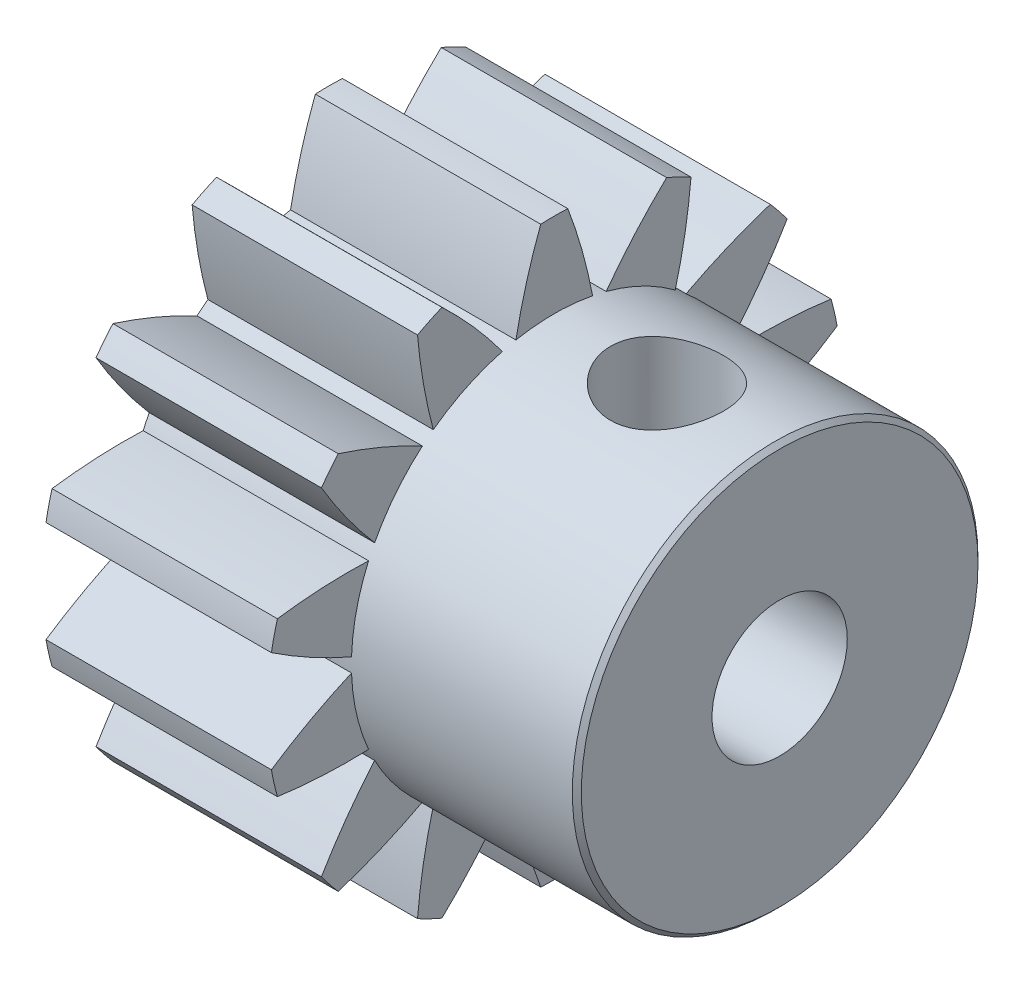
from build123d import *

# Parameters (mm, degrees)
SKETCH1_R           = 4.5
SKETCH1_R_2         = 1.5
BOSS_EXTRUDE1_DEPTH = 10
BOSS_EXTRUDE2_DEPTH = 5
CIRPATTERN1_COUNT   = 14
CHAMFER1_SIZE       = 0.1
SKETCH2_R           = 1.25
CUT_EXTRUDE1_DEPTH  = 14.417030319
CUT_EXTRUDE2_DEPTH  = 0.01


with BuildPart() as part:
    # Sketch1 → Boss-Extrude1 (new body)
    with BuildSketch(Plane(origin=(0, 0, 0), x_dir=(0, 0, -1), z_dir=(1, 0, 0))):
        Circle(SKETCH1_R)
        Circle(SKETCH1_R_2, mode=Mode.SUBTRACT)
    extrude(amount=BOSS_EXTRUDE1_DEPTH)

    # Sketch1_3 → Boss-Extrude2 (add)
    with BuildSketch(Plane(origin=(0, 0, 0), x_dir=(0, 0, -1), z_dir=(1, 0, 0))):
        with BuildLine():
            ThreePointArc((-0.85, 4.418993098), (0, 3.393196379), (0.85, 4.418993098))
            ThreePointArc((0.85, 4.418993098), (0.617982771, 5.405595095), (0.3, 6.367937264))
            ThreePointArc((0.3, 6.367937264), (0, 6.375), (-0.3, 6.367937264))
            ThreePointArc((-0.3, 6.367937264), (-0.617982771, 5.405595095), (-0.85, 4.418993098))
        make_face()
    boss_extrude2 = extrude(amount=BOSS_EXTRUDE2_DEPTH)

    # CirPattern1: Boss-Extrude2 ×14 about axis
    cirpattern1_axis = Axis((10, 0, 0), (-1, 0, 0))
    for i in range(1, CIRPATTERN1_COUNT):
        add(boss_extrude2.rotate(cirpattern1_axis, i * 360 / CIRPATTERN1_COUNT))

    # Chamfer1
    chamfer1_edges = [part.edges().sort_by_distance(p)[0] for p in [
        (10, 0, 4.5),
    ]]
    chamfer(chamfer1_edges, length=CHAMFER1_SIZE)

    # Sketch2 → Cut-Extrude1 (cut, through all)
    with BuildSketch(Plane(origin=(0, 0, 0), x_dir=(1, 0, 0), z_dir=(0, 1, 0))):
        with Locations((7.5, 0)):
            Circle(SKETCH2_R)
    extrude(amount=CUT_EXTRUDE1_DEPTH, mode=Mode.SUBTRACT)

    # Sketch3 → Cut-Extrude2 (cut)
    # profile 1 of 6: a face of its own
    with BuildSketch(Plane.ZY):
        with BuildLine():
            Line((3.696183293, 1.353338585), (3.76559435, 1.064576566))
            add(Edge.make_bspline(
                [(3.76559435, 1.064576566), (3.77037167, 1.044660811), (3.779502695, 1.006595267), (3.791496189, 0.951772239), (3.80174489, 0.90189395), (3.810274475, 0.856951074), (3.816624635, 0.81685637), (3.821136168, 0.781692215), (3.824228842, 0.751331364), (3.824407225, 0.732651366), (3.824488581, 0.724131854)],
                knots=[0, 0, 0, 0, 1.420106792, 2.7142901, 3.891117153, 4.950882503, 5.886029369, 6.705261392, 7.409499822, 8, 8, 8, 8], degree=3))
            add(Edge.make_bspline(
                [(3.824488581, 0.724131854), (3.824298798, 0.713299913), (3.823923222, 0.691863781), (3.819683757, 0.660265307), (3.81389973, 0.629564749), (3.805288674, 0.599860763), (3.794631953, 0.57103397), (3.781089101, 0.543290147), (3.766005343, 0.516076204), (3.747841429, 0.490412668), (3.727860243, 0.465999654), (3.705487855, 0.44369448), (3.681058056, 0.423448751), (3.654386915, 0.405450772), (3.62590372, 0.389047347), (3.59487265, 0.37536351), (3.562036386, 0.363164909), (3.538993849, 0.357242315), (3.5273131, 0.354240027)],
                knots=[0, 0, 0, 0, 1.009742343, 1.998254008, 2.969393097, 3.921652167, 4.879577864, 5.83238679, 6.798885613, 7.778615852, 8.760748813, 9.738516915, 10.720649875, 11.715762546, 12.736724355, 13.782145576, 14.875722736, 16, 16, 16, 16], degree=3))
            add(Edge.make_bspline(
                [(3.5273131, 0.354240027), (3.515426007, 0.351662324), (3.492182734, 0.346622046), (3.457416611, 0.342136571), (3.423669484, 0.340289689), (3.390780456, 0.341064117), (3.358902983, 0.345019169), (3.328044085, 0.351687405), (3.298163619, 0.360883889), (3.269628328, 0.373397844), (3.242169647, 0.388136984), (3.216117148, 0.405210027), (3.191527287, 0.424564609), (3.168764436, 0.446424515), (3.146911749, 0.470034725), (3.127180501, 0.496540221), (3.108396609, 0.524872618), (3.097655659, 0.545246012), (3.092216946, 0.555562143)],
                knots=[0, 0, 0, 0, 1.117505492, 2.185099841, 3.217588868, 4.22136312, 5.204451967, 6.165000207, 7.119974362, 8.072460675, 9.023878779, 9.981334311, 10.93163842, 11.895357376, 12.879307825, 13.884558372, 14.928839729, 16, 16, 16, 16], degree=3))
            add(Edge.make_bspline(
                [(3.092216946, 0.555562143), (3.088132773, 0.564140946), (3.079162793, 0.582982381), (3.066363201, 0.61455049), (3.053264076, 0.651786736), (3.039934444, 0.694593475), (3.025453638, 0.74262799), (3.010388619, 0.796186534), (2.995167454, 0.855443572), (2.985096318, 0.896896209), (2.979837139, 0.918542912)],
                knots=[0, 0, 0, 0, 0.599028215, 1.315632346, 2.146623072, 3.087410317, 4.142418399, 5.310125699, 6.595338879, 8, 8, 8, 8], degree=3))
            Line((2.979837139, 0.918542912), (2.954897235, 1.022208777))
            Line((2.954897235, 1.022208777), (2.280618389, 0.860249643))
            Line((2.280618389, 0.860249643), (2.24576262, 1.005081373))
            Line((2.24576262, 1.005081373), (3.696183293, 1.353338585))
        make_face()
        with BuildLine():
            Line((3.590113581, 1.174853008), (3.097024639, 1.056463585))
            Line((3.097024639, 1.056463585), (3.152914062, 0.810069354))
            add(Edge.make_bspline(
                [(3.152914062, 0.810069354), (3.155860013, 0.798135216), (3.161572464, 0.77499391), (3.170787666, 0.741795387), (3.180458979, 0.711242954), (3.190311394, 0.68349567), (3.20016808, 0.658216601), (3.210625253, 0.63589994), (3.221184781, 0.616088129), (3.235303155, 0.593596201), (3.255012815, 0.569205569), (3.28240234, 0.54502088), (3.312831572, 0.525158641), (3.346191435, 0.510233989), (3.381428388, 0.500235604), (3.417811812, 0.496192703), (3.454710971, 0.496763884), (3.478984012, 0.501689668), (3.491255408, 0.504179931)],
                knots=[0, 0, 0, 0, 1.134875419, 2.20061973, 3.180367898, 4.092916849, 4.918894509, 5.684255937, 6.366939641, 6.990370405, 8.134214937, 9.247753563, 10.350682225, 11.4764791, 12.609544629, 13.717578753, 14.84610686, 16, 16, 16, 16], degree=3))
            add(Edge.make_bspline(
                [(3.491255408, 0.504179931), (3.503092586, 0.507547531), (3.526492555, 0.514204669), (3.559327761, 0.530052041), (3.588968678, 0.550933669), (3.61589329, 0.575327399), (3.63906331, 0.6031269), (3.65728075, 0.633636901), (3.670048896, 0.666342631), (3.676468398, 0.695326093), (3.678684033, 0.720386305), (3.679413699, 0.741673184), (3.677894561, 0.765335193), (3.675516304, 0.791287317), (3.671981132, 0.81979835), (3.666358891, 0.850495829), (3.659855866, 0.883701137), (3.654494688, 0.90644036), (3.651712139, 0.918242431)],
                knots=[0, 0, 0, 0, 1.164641121, 2.302285783, 3.434374343, 4.589930822, 5.735859126, 6.850830588, 7.941791502, 9.049468073, 9.650101826, 10.324224693, 11.065489516, 11.894683428, 12.794070503, 13.786450834, 14.851127726, 16, 16, 16, 16], degree=3))
            Line((3.651712139, 0.918242431), (3.590113581, 1.174853008))
        make_face(mode=Mode.SUBTRACT)
    # profile 2 of 6: a face of its own
    with BuildSketch(Plane.ZY):
        with BuildLine():
            Line((2.38117998, 2.522545505), (2.288331422, 2.631019063))
            add(Edge.make_bspline(
                [(2.288331422, 2.631019063), (2.302558409, 2.642112094), (2.33055903, 2.663944667), (2.375210694, 2.691415342), (2.420460909, 2.714512141), (2.466592113, 2.732774811), (2.513802566, 2.745563434), (2.561646804, 2.754254193), (2.610505363, 2.757318588), (2.659696126, 2.756246137), (2.708421688, 2.750291871), (2.755554129, 2.73961618), (2.800935874, 2.72509532), (2.843957761, 2.705249524), (2.885266368, 2.681547334), (2.923952309, 2.652568252), (2.961314634, 2.619934911), (2.98369129, 2.59500801), (2.995062191, 2.582341178)],
                knots=[0, 0, 0, 0, 1.096280449, 2.157627114, 3.181764335, 4.182693667, 5.168236385, 6.151518248, 7.134366187, 8.139585183, 9.139773059, 10.113502013, 11.074577628, 12.031262583, 12.989168109, 13.964894965, 14.965842827, 16, 16, 16, 16], degree=3))
            add(Edge.make_bspline(
                [(2.995062191, 2.582341178), (3.005771135, 2.569437807), (3.026762737, 2.544144701), (3.052703797, 2.503219512), (3.074521409, 2.46196667), (3.092045324, 2.419953989), (3.103978555, 2.376824098), (3.111198213, 2.332899661), (3.114005706, 2.288184261), (3.111709932, 2.243102154), (3.10553359, 2.198632548), (3.095252359, 2.155799971), (3.081418003, 2.115037727), (3.063893519, 2.076241667), (3.042486634, 2.039529718), (3.017377252, 2.004869391), (2.988804455, 1.97203598), (2.9670349, 1.952513676), (2.955999691, 1.942617621)],
                knots=[0, 0, 0, 0, 1.123473806, 2.202226089, 3.241768798, 4.250854748, 5.24822596, 6.235412689, 7.231335351, 8.246661292, 9.25735549, 10.238100213, 11.19606276, 12.139958311, 13.088074462, 14.040676712, 15.006799063, 16, 16, 16, 16], degree=3))
            add(Edge.make_bspline(
                [(2.955999691, 1.942617621), (2.93970516, 1.929521972), (2.907370194, 1.90353489), (2.853152721, 1.873074713), (2.79606504, 1.84896867), (2.745240087, 1.835204472), (2.701432735, 1.827328857), (2.664118437, 1.822599638), (2.622606522, 1.819159744), (2.576925252, 1.816398391), (2.527023392, 1.814989671), (2.472923447, 1.814714854), (2.414623441, 1.815704178), (2.374367613, 1.816965107), (2.353535749, 1.817617621)],
                knots=[0, 0, 0, 0, 1.189950895, 2.361345635, 3.530985644, 4.715347917, 5.353727711, 6.067617875, 6.858549572, 7.727965667, 8.676229375, 9.704016878, 10.811858751, 12, 12, 12, 12], degree=3))
            Line((2.353535749, 1.817617621), (1.807862672, 1.838951755))
            Line((1.807862672, 1.838951755), (2.25617998, 1.316115217))
            Line((2.25617998, 1.316115217), (2.14680498, 1.222365217))
            Line((2.14680498, 1.222365217), (1.487550172, 1.991595986))
            Line((1.487550172, 1.991595986), (2.325591037, 1.959444544))
            add(Edge.make_bspline(
                [(2.325591037, 1.959444544), (2.345920715, 1.958546058), (2.385067532, 1.956815933), (2.441473011, 1.95588179), (2.493159665, 1.954939522), (2.540038712, 1.955784392), (2.582135211, 1.956673871), (2.619510631, 1.959144561), (2.65220231, 1.962318128), (2.689155289, 1.96770549), (2.730902852, 1.978171244), (2.777398192, 1.996196451), (2.820761937, 2.019966293), (2.846388316, 2.040292638), (2.859244883, 2.050490217)],
                knots=[0, 0, 0, 0, 1.319519105, 2.540865323, 3.658089869, 4.671401321, 5.581079737, 6.388140645, 7.099697284, 7.710543071, 8.808514353, 9.881987577, 10.937408622, 12, 12, 12, 12], degree=3))
            add(Edge.make_bspline(
                [(2.859244883, 2.050490217), (2.866883876, 2.057470035), (2.881912491, 2.07120182), (2.902035946, 2.093856794), (2.918779015, 2.118489335), (2.933371088, 2.144202868), (2.944779557, 2.171711243), (2.953933697, 2.200511224), (2.959826466, 2.231075215), (2.963007829, 2.262643546), (2.9638531, 2.294539128), (2.960917816, 2.326007403), (2.955628288, 2.356721393), (2.947284188, 2.38661518), (2.935312435, 2.415416277), (2.920410421, 2.443326809), (2.903241565, 2.470964331), (2.889201673, 2.487843503), (2.882081422, 2.496403678)],
                knots=[0, 0, 0, 0, 0.999905498, 1.967169876, 2.920573645, 3.874124881, 4.819977307, 5.793761178, 6.790615242, 7.82240207, 8.858540536, 9.869215813, 10.872023256, 11.868124764, 12.862389532, 13.8801353, 14.924922668, 16, 16, 16, 16], degree=3))
            add(Edge.make_bspline(
                [(2.882081422, 2.496403678), (2.874335544, 2.505081566), (2.859072951, 2.522180606), (2.833635619, 2.544632209), (2.807227044, 2.564363682), (2.779285777, 2.580727147), (2.750062192, 2.593965737), (2.719554708, 2.604207719), (2.687773943, 2.611543345), (2.654825291, 2.615345454), (2.621216886, 2.615927358), (2.587268142, 2.613284355), (2.553206916, 2.606765978), (2.518848624, 2.597224809), (2.48441403, 2.583779502), (2.449834842, 2.566920718), (2.415183563, 2.54634492), (2.392699066, 2.530607818), (2.38117998, 2.522545505)],
                knots=[0, 0, 0, 0, 0.999261768, 1.968960255, 2.911042676, 3.829652525, 4.746848662, 5.664529745, 6.592016422, 7.545832305, 8.510432225, 9.477987221, 10.467705008, 11.487314743, 12.539564799, 13.641015056, 14.791462839, 16, 16, 16, 16], degree=3))
        make_face()
    # profile 3 of 6: a face of its own
    with BuildSketch(Plane.ZY):
        with BuildLine():
            Line((1.073035574, 3.427396583), (0.932110094, 3.48478841))
            add(Edge.make_bspline(
                [(0.932110094, 3.48478841), (0.941136662, 3.497354214), (0.958787037, 3.52192514), (0.987875104, 3.555547984), (1.017749608, 3.586197181), (1.048772077, 3.613633613), (1.081601126, 3.63712004), (1.115204624, 3.657597818), (1.149956947, 3.675042136), (1.186017364, 3.688358014), (1.222606854, 3.698605351), (1.259401275, 3.70553074), (1.296304263, 3.709317315), (1.333211415, 3.709077719), (1.370242924, 3.706248777), (1.407347365, 3.699489575), (1.444515595, 3.689316537), (1.468833202, 3.680192105), (1.481088459, 3.675593699)],
                knots=[0, 0, 0, 0, 1.173461643, 2.294563878, 3.369425321, 4.419689001, 5.432178396, 6.427986429, 7.403459542, 8.37748086, 9.340019017, 10.283556944, 11.215236072, 12.150040765, 13.080354976, 14.029994875, 15.007183653, 16, 16, 16, 16], degree=3))
            add(Edge.make_bspline(
                [(1.481088459, 3.675593699), (1.498534515, 3.667804468), (1.533100686, 3.652371531), (1.580924187, 3.621839632), (1.624331479, 3.585932784), (1.663007773, 3.545190963), (1.695946681, 3.50069553), (1.722381137, 3.453468456), (1.74197067, 3.404095529), (1.75367055, 3.353008753), (1.759284639, 3.301929866), (1.757771655, 3.251788295), (1.749616805, 3.203197887), (1.738660986, 3.172559234), (1.733191824, 3.157264372)],
                knots=[0, 0, 0, 0, 1.075149132, 2.130211422, 3.184262343, 4.241931608, 5.286942786, 6.294795152, 7.282868146, 8.26827928, 9.238468594, 10.16989983, 11.086411216, 12, 12, 12, 12], degree=3))
            add(Edge.make_bspline(
                [(1.733191824, 3.157264372), (1.726763428, 3.142942618), (1.714139064, 3.114816937), (1.688881475, 3.076565323), (1.658779687, 3.043187533), (1.624156798, 3.014383801), (1.584920479, 2.990106067), (1.54098726, 2.970725284), (1.492638556, 2.955421064), (1.458446186, 2.949618099), (1.440824036, 2.946627353)],
                knots=[0, 0, 0, 0, 0.993590812, 1.951256749, 2.890573757, 3.832460602, 4.795914361, 5.804495644, 6.86847542, 8, 8, 8, 8], degree=3))
            add(Edge.make_bspline(
                [(1.440824036, 2.946627353), (1.454025092, 2.933027228), (1.480041681, 2.906224155), (1.512049691, 2.860906675), (1.538726252, 2.813255325), (1.550582727, 2.779169702), (1.556509132, 2.76213216)],
                knots=[0, 0, 0, 0, 1.032465958, 2.034779866, 3.01769377, 4, 4, 4, 4], degree=3))
            add(Edge.make_bspline(
                [(1.556509132, 2.76213216), (1.560037089, 2.750067841), (1.567024493, 2.726173483), (1.573492492, 2.689823604), (1.576836086, 2.653834613), (1.577122646, 2.618255321), (1.574532566, 2.582931176), (1.568322209, 2.547992802), (1.55951213, 2.513196807), (1.55092698, 2.490723897), (1.546593267, 2.479379756)],
                knots=[0, 0, 0, 0, 1.044106844, 2.067937838, 3.062827906, 4.045204899, 5.022099144, 6.002039219, 6.991445833, 8, 8, 8, 8], degree=3))
            add(Edge.make_bspline(
                [(1.546593267, 2.479379756), (1.538033053, 2.460251425), (1.520936205, 2.422047451), (1.485233838, 2.369939803), (1.443174756, 2.322003768), (1.402614581, 2.286399865), (1.367186638, 2.261127991), (1.33993099, 2.243463303), (1.311509704, 2.228457341), (1.282242764, 2.215538573), (1.252263657, 2.204425042), (1.221497077, 2.195225415), (1.189873586, 2.188856481), (1.146924465, 2.182228226), (1.092169338, 2.179942275), (1.025961987, 2.185417031), (0.959444783, 2.199448201), (0.916415784, 2.215309832), (0.894549997, 2.223370141)],
                knots=[0, 0, 0, 0, 1.2866528, 2.569761502, 3.866110613, 5.201862281, 5.877154398, 6.541912128, 7.197790889, 7.851409293, 8.508242018, 9.163194397, 9.82405893, 10.490527016, 11.834859164, 13.182349143, 14.568171386, 16, 16, 16, 16], degree=3))
            add(Edge.make_bspline(
                [(0.894549997, 2.223370141), (0.880110594, 2.229535478), (0.851688152, 2.241671294), (0.811765898, 2.263768723), (0.77490121, 2.288081901), (0.741358966, 2.315000238), (0.710879204, 2.344250155), (0.68338619, 2.375839091), (0.659212049, 2.41010825), (0.638170043, 2.446673205), (0.6207056, 2.485641902), (0.606835922, 2.526571046), (0.596899349, 2.569547051), (0.590931073, 2.614419104), (0.588985198, 2.661261825), (0.59047292, 2.709976999), (0.595955234, 2.760681851), (0.602257987, 2.794820115), (0.605487497, 2.812312449)],
                knots=[0, 0, 0, 0, 1.044426688, 2.055843657, 3.032090107, 3.980559134, 4.914104095, 5.840384749, 6.763372997, 7.701050496, 8.64395068, 9.601048902, 10.572915293, 11.575128843, 12.609486112, 13.689969795, 14.816348125, 16, 16, 16, 16], degree=3))
            Line((0.605487497, 2.812312449), (0.740703844, 2.757324468))
            add(Edge.make_bspline(
                [(0.740703844, 2.757324468), (0.739253615, 2.745218125), (0.736442994, 2.721755375), (0.734779082, 2.687334435), (0.734567182, 2.654924998), (0.736731658, 2.624411256), (0.740595453, 2.595793521), (0.746160417, 2.569000719), (0.753955702, 2.544141105), (0.76079431, 2.528702654), (0.764141344, 2.521146583)],
                knots=[0, 0, 0, 0, 1.216244907, 2.357148744, 3.436511083, 4.448336158, 5.406623508, 6.316141131, 7.175865753, 8, 8, 8, 8], degree=3))
            add(Edge.make_bspline(
                [(0.764141344, 2.521146583), (0.768843998, 2.512109531), (0.778233564, 2.494065682), (0.795960575, 2.469256667), (0.815610089, 2.445800141), (0.837793997, 2.42416852), (0.862762678, 2.40464582), (0.889732351, 2.386491434), (0.919443003, 2.370573881), (0.940356491, 2.361446452), (0.951040382, 2.356783603)],
                knots=[0, 0, 0, 0, 0.959089067, 1.914967124, 2.866219145, 3.840884694, 4.82867382, 5.849777742, 6.901534692, 8, 8, 8, 8], degree=3))
            add(Edge.make_bspline(
                [(0.951040382, 2.356783603), (0.96338724, 2.352061722), (0.987473167, 2.342850401), (1.024094432, 2.332915224), (1.059989066, 2.326500461), (1.095328446, 2.323709547), (1.129943113, 2.324712691), (1.163951832, 2.32872482), (1.197016964, 2.33705856), (1.229132745, 2.348397499), (1.259512929, 2.362804624), (1.287923995, 2.379318551), (1.313883413, 2.398038532), (1.337487441, 2.418740296), (1.358295026, 2.441914115), (1.377055598, 2.46679528), (1.393123451, 2.494049323), (1.401653252, 2.513440456), (1.405968267, 2.523249949)],
                knots=[0, 0, 0, 0, 1.172778833, 2.287826355, 3.362150131, 4.405418369, 5.428180362, 6.431671934, 7.438662538, 8.448161802, 9.45039231, 10.418647132, 11.361214002, 12.287070745, 13.19968554, 14.120749057, 15.049333677, 16, 16, 16, 16], degree=3))
            add(Edge.make_bspline(
                [(1.405968267, 2.523249949), (1.410780186, 2.536755835), (1.420373785, 2.563682731), (1.427531022, 2.606198248), (1.427957199, 2.649621576), (1.4224813, 2.693247388), (1.411576294, 2.736228554), (1.394376489, 2.776911368), (1.371342152, 2.814712183), (1.34780948, 2.844067393), (1.325051974, 2.866155008), (1.305195554, 2.883490415), (1.281904409, 2.900335359), (1.256016269, 2.917881113), (1.227093922, 2.935542078), (1.195338918, 2.953502865), (1.160564121, 2.971646126), (1.136175414, 2.983264863), (1.123516344, 2.989295622)],
                knots=[0, 0, 0, 0, 1.124186424, 2.241307977, 3.366071972, 4.523013804, 5.68470411, 6.837199961, 7.976932333, 9.151173802, 9.779613117, 10.465468428, 11.21892274, 12.034732754, 12.920936244, 13.878882863, 14.899024404, 16, 16, 16, 16], degree=3))
            Line((1.123516344, 2.989295622), (1.174898555, 3.115798026))
            add(Edge.make_bspline(
                [(1.174898555, 3.115798026), (1.19051661, 3.109862074), (1.221201112, 3.09819982), (1.268290731, 3.086582752), (1.314905982, 3.079861909), (1.360416459, 3.07808154), (1.403628099, 3.080714331), (1.442917592, 3.088677319), (1.478236214, 3.100070896), (1.508781112, 3.116899317), (1.53529082, 3.137327984), (1.557818903, 3.160680519), (1.576484133, 3.187125848), (1.585356343, 3.206578946), (1.589862497, 3.216459083)],
                knots=[0, 0, 0, 0, 1.264680697, 2.484694536, 3.664969982, 4.826688221, 5.929430557, 6.935286327, 7.856611217, 8.729160465, 9.562291531, 10.383277231, 11.178874081, 12, 12, 12, 12], degree=3))
            add(Edge.make_bspline(
                [(1.589862497, 3.216459083), (1.592621835, 3.223920864), (1.598096141, 3.238724448), (1.60350816, 3.261603594), (1.606159184, 3.284687944), (1.606587902, 3.307871164), (1.603983032, 3.331212665), (1.599301134, 3.35472974), (1.591505463, 3.378265846), (1.581865215, 3.401836953), (1.56938192, 3.42449637), (1.555483927, 3.446362952), (1.538794397, 3.46611245), (1.520210807, 3.484328153), (1.49988187, 3.501136875), (1.477340203, 3.516317441), (1.452744444, 3.529782922), (1.43527788, 3.537405049), (1.426400959, 3.541278795)],
                knots=[0, 0, 0, 0, 0.942886286, 1.870611792, 2.779671044, 3.694377883, 4.613930783, 5.559730562, 6.532664774, 7.549631086, 8.575369572, 9.596696853, 10.617194909, 11.633536698, 12.679907084, 13.740740404, 14.851790874, 16, 16, 16, 16], degree=3))
            add(Edge.make_bspline(
                [(1.426400959, 3.541278795), (1.411722504, 3.546624459), (1.383114754, 3.557042953), (1.338479104, 3.563367592), (1.294496569, 3.563077514), (1.25844997, 3.555870852), (1.229992014, 3.546298631), (1.208315444, 3.536550445), (1.186229691, 3.524516893), (1.16417594, 3.509600466), (1.141408199, 3.492798532), (1.118815485, 3.473213942), (1.095699235, 3.451409032), (1.080767995, 3.435589185), (1.073035574, 3.427396583)],
                knots=[0, 0, 0, 0, 1.404400927, 2.737123946, 4.037042158, 5.35231948, 6.028813348, 6.740006402, 7.491364433, 8.292474289, 9.137341572, 10.040020627, 10.984988252, 12, 12, 12, 12], degree=3))
        make_face()
    # profile 4 of 6: a face of its own
    with BuildSketch(Plane.ZY):
        Polygon((-1.347751096, 3.590605352), (-1.384109269, 3.731530833), (-0.588436192, 3.93736016), (-0.552078019, 3.796434679), (-0.875395327, 3.712600545), (-0.5367535, 2.403105352), (-0.684590038, 2.364944295), (-1.023231865, 3.674439487), align=None)
    # profile 5 of 6: a face of its own
    with BuildSketch(Plane.ZY):
        Polygon((-2.182728115, 3.314663411), (-2.158689654, 3.333293219), (-1.523773788, 2.515084084), (-1.381646385, 2.625360526), (-1.294206481, 2.512680238), (-1.436333885, 2.402403796), (-1.224795423, 2.129567257), (-1.342283404, 2.038521584), (-1.553821865, 2.311358122), (-2.114819461, 1.875961488), align=None)
        Polygon((-1.641261769, 2.424038411), (-2.020768981, 2.913221103), (-1.986814654, 2.155709084), align=None, mode=Mode.SUBTRACT)
    # profile 6 of 6: a face of its own
    with BuildSketch(Plane.ZY):
        Polygon((-3.614335075, 1.531556645), (-3.48753219, 1.794777799), (-2.14768844, 1.149946068), (-2.211690844, 1.016833087), (-3.420224498, 1.598563857), (-3.521486517, 1.388227318), align=None)
    extrude(amount=-CUT_EXTRUDE2_DEPTH, mode=Mode.SUBTRACT)


solid = part.part
